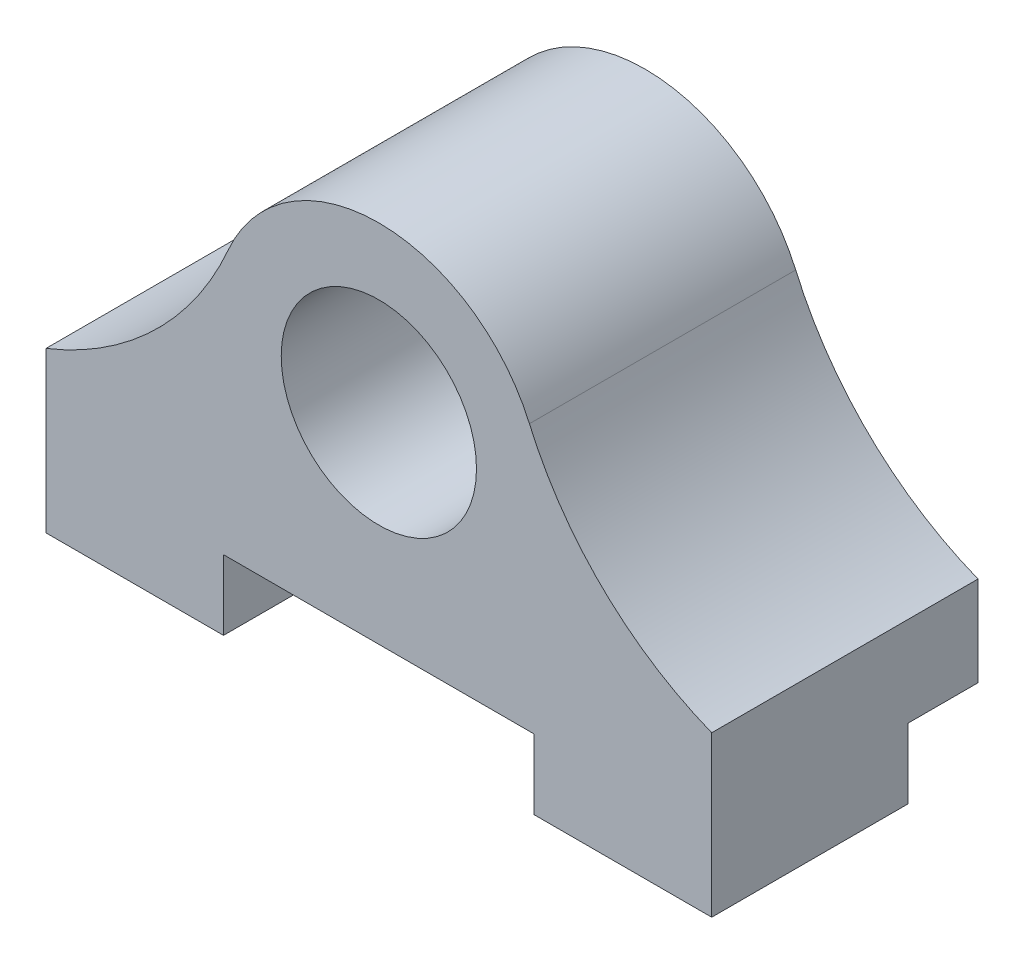
from build123d import *

# Parameters (mm, degrees)
SKETCH1_R               = 4.4
BOSS_EXTRUDE1_DEPTH     = 10
SKETCH1_2_R             = 4.4
BOSS_EXTRUDE2_DEPTH     = 2
SKETCH3_W               = 30
SKETCH3_H               = 12
BOSS_EXTRUDE4_DEPTH     = 7.2
CUT_EXTRUDE2_START      = -12.2
SKETCH2_R               = 1.65
CUT_EXTRUDE2_DEPTH      = 8
SKETCH5_W               = 30
SKETCH5_H               = 3.15
CUT_EXTRUDE3_DEPTH      = 23.756098084
CUT_EXTRUDE3_DEPTH_BACK = 3.15
SKETCH6_W               = 14
SKETCH6_H               = 3.15
CUT_EXTRUDE4_DEPTH      = 23.756098084
CUT_EXTRUDE4_DEPTH_BACK = 23.756098084


with BuildPart() as part:
    # Sketch1 → Boss-Extrude1 (new body)
    with BuildSketch(Plane.XY):
        with BuildLine():
            Line((-15, -5), (15, -5))
            ThreePointArc((15, -5), (10.104984149, -1.836764635), (6.785093744, 2.953388374))
            ThreePointArc((6.785093744, 2.953388374), (0, 7.4), (-6.785093744, 2.953388374))
            ThreePointArc((-6.785093744, 2.953388374), (-10.104984149, -1.836764635), (-15, -5))
        make_face()
        Circle(SKETCH1_R, mode=Mode.SUBTRACT)
    extrude(amount=BOSS_EXTRUDE1_DEPTH)

    # Sketch1_2 → Boss-Extrude2 (add)
    with BuildSketch(Plane.XY):
        with BuildLine():
            ThreePointArc((-6.785093744, 2.953388374), (0, 7.4), (6.785093744, 2.953388374))
            ThreePointArc((6.785093744, 2.953388374), (10.104984149, -1.836764635), (15, -5))
            Line((15, -5), (-15, -5))
            ThreePointArc((-15, -5), (-10.104984149, -1.836764635), (-6.785093744, 2.953388374))
        make_face()
        Circle(SKETCH1_2_R, mode=Mode.SUBTRACT)
        Circle(SKETCH1_2_R)
    extrude(amount=-BOSS_EXTRUDE2_DEPTH)

    # Sketch3 → Boss-Extrude4 (add)
    with BuildSketch(Plane.XZ.offset(5)):
        with Locations((0, 4)):
            Rectangle(SKETCH3_W, SKETCH3_H)
    extrude(amount=BOSS_EXTRUDE4_DEPTH)

    # Sketch2 → Cut-Extrude2 (cut)
    with BuildSketch(Plane(origin=(0, 0, 0), x_dir=(1, 0, 0), z_dir=(0, 1, 0)).offset(CUT_EXTRUDE2_START)):
        with Locations(Location((-11.5, -4, 0), (0, 0, 90))):
            Circle(SKETCH2_R)
        with Locations(Location((11.5, -4, 0), (0, 0, 90))):
            Circle(SKETCH2_R)
    extrude(amount=CUT_EXTRUDE2_DEPTH, mode=Mode.SUBTRACT)

    # Sketch5 → Cut-Extrude3 (cut, two sides)
    with BuildSketch(Plane(origin=(0, 0, -2), x_dir=(-1, 0, 0), z_dir=(0, 0, -1))) as cut_extrude3_sk:
        with Locations((0, -10.625)):
            Rectangle(SKETCH5_W, SKETCH5_H)
    extrude(amount=CUT_EXTRUDE3_DEPTH, mode=Mode.SUBTRACT)
    extrude(cut_extrude3_sk.sketch, amount=-CUT_EXTRUDE3_DEPTH_BACK, mode=Mode.SUBTRACT)

    # Sketch6 → Cut-Extrude4 (cut, two sides)
    with BuildSketch(Plane.XY.offset(10)) as cut_extrude4_sk:
        with Locations((0, -10.625)):
            Rectangle(SKETCH6_W, SKETCH6_H)
    extrude(amount=CUT_EXTRUDE4_DEPTH, mode=Mode.SUBTRACT)
    extrude(cut_extrude4_sk.sketch, amount=-CUT_EXTRUDE4_DEPTH_BACK, mode=Mode.SUBTRACT)


solid = part.part
